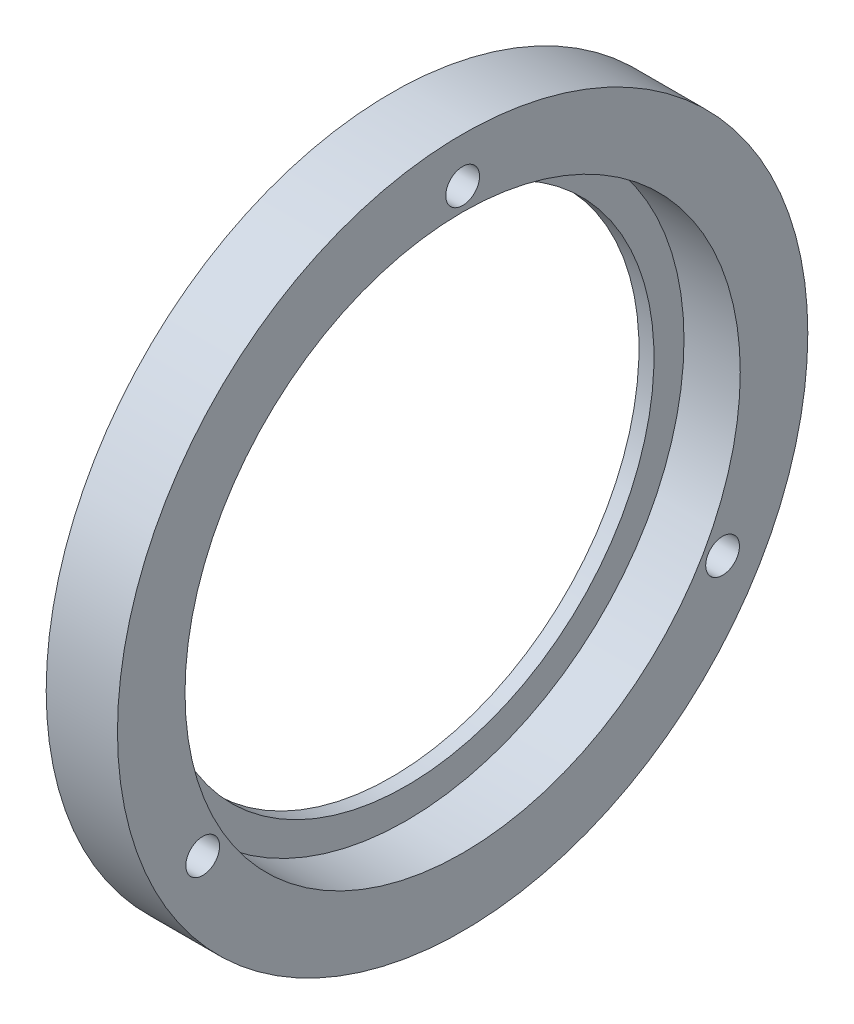
from build123d import *

# Parameters (mm, degrees)
ESQUISSE2_R                  = 2.25
ENL_V_MAT_EXTRU_1_DEPTH      = 10.5
R_P_TITION_CIRCULAIRE1_COUNT = 3


with BuildPart() as part:
    # Esquisse1 → Base-Révolution (revolve)
    with BuildSketch(Plane.XY):
        Polygon((0, 33), (0, 46), (9.5, 46), (9.5, 37), (2, 37), (2, 33), align=None)
    revolve(axis=Axis((0, 0, 0), (1, 0, 0)))

    # Esquisse2 → Enlèv. mat.-Extru.1 (cut, through all)
    with BuildSketch(Plane.ZY):
        with Locations((0, 40)):
            Circle(ESQUISSE2_R)
    enl_v_mat_extru_1 = extrude(amount=-ENL_V_MAT_EXTRU_1_DEPTH, mode=Mode.SUBTRACT)

    # Répétition circulaire1: Enlèv. mat.-Extru.1 ×3 about axis
    r_p_tition_circulaire1_axis = Axis((0, 0, 0), (1, 0, 0))
    for i in range(1, R_P_TITION_CIRCULAIRE1_COUNT):
        add(enl_v_mat_extru_1.rotate(r_p_tition_circulaire1_axis, i * 360 / R_P_TITION_CIRCULAIRE1_COUNT), mode=Mode.SUBTRACT)


solid = part.part
